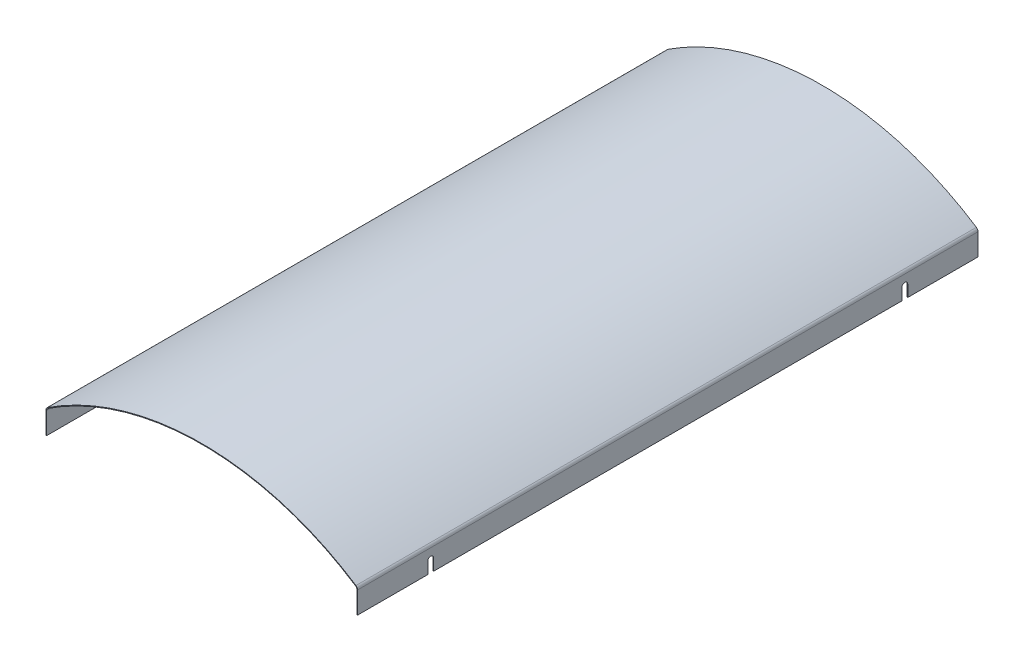
from build123d import *

# Parameters (mm, degrees)
EXTRUDE_THIN1_DEPTH = 673.1
CUT_EXTRUDE2_DEPTH  = 677.1


with BuildPart() as part:
    # Sketch1 → Extrude-Thin1 (new body, symmetric)
    with BuildSketch(Plane.XY):
        with BuildLine():
            Line((-336.55, 1067.077736577), (-336.55, 1114.454951942))
            ThreePointArc((-336.55, 1114.454951942), (-335.785416867, 1117.475815795), (-333.675789474, 1119.769214594))
            ThreePointArc((-333.675789474, 1119.769214594), (-174.087631358, 1193.813707994), (0, 1219.2))
            Line((0, 1219.2), (0, 1220.7))
            ThreePointArc((0, 1220.7), (-174.515996593, 1195.251241724), (-334.496842105, 1121.024552228))
            ThreePointArc((-334.496842105, 1121.024552228), (-337.104806678, 1118.189405682), (-338.05, 1114.454951942))
            Line((-338.05, 1114.454951942), (-338.05, 1067.077736577))
            Line((-338.05, 1067.077736577), (-336.55, 1067.077736577))
        make_face()
    extrude_thin1 = extrude(amount=EXTRUDE_THIN1_DEPTH, both=True)

    # Mirror1: Extrude-Thin1 across plane
    add(extrude_thin1.mirror(Plane(origin=(0, 0, 0), x_dir=(0, 0, 1), z_dir=(1, 0, 0))))

    # Sketch3 → Cut-Extrude2 (cut, through all)
    with BuildSketch(Plane.ZY.offset(338.05)):
        with BuildLine():
            Line((508, 1092.2), (508, 1067.077736577))
            Line((508, 1067.077736577), (520.7, 1067.077736577))
            Line((520.7, 1067.077736577), (520.7, 1092.2))
            ThreePointArc((520.7, 1092.2), (514.35, 1098.55), (508, 1092.2))
        make_face()
        with BuildLine():
            Line((-520.7, 1067.077736577), (-508, 1067.077736577))
            Line((-508, 1067.077736577), (-508, 1092.2))
            ThreePointArc((-508, 1092.2), (-514.35, 1098.55), (-520.7, 1092.2))
            Line((-520.7, 1092.2), (-520.7, 1067.077736577))
        make_face()
    extrude(amount=-CUT_EXTRUDE2_DEPTH, mode=Mode.SUBTRACT)


solid = part.part
